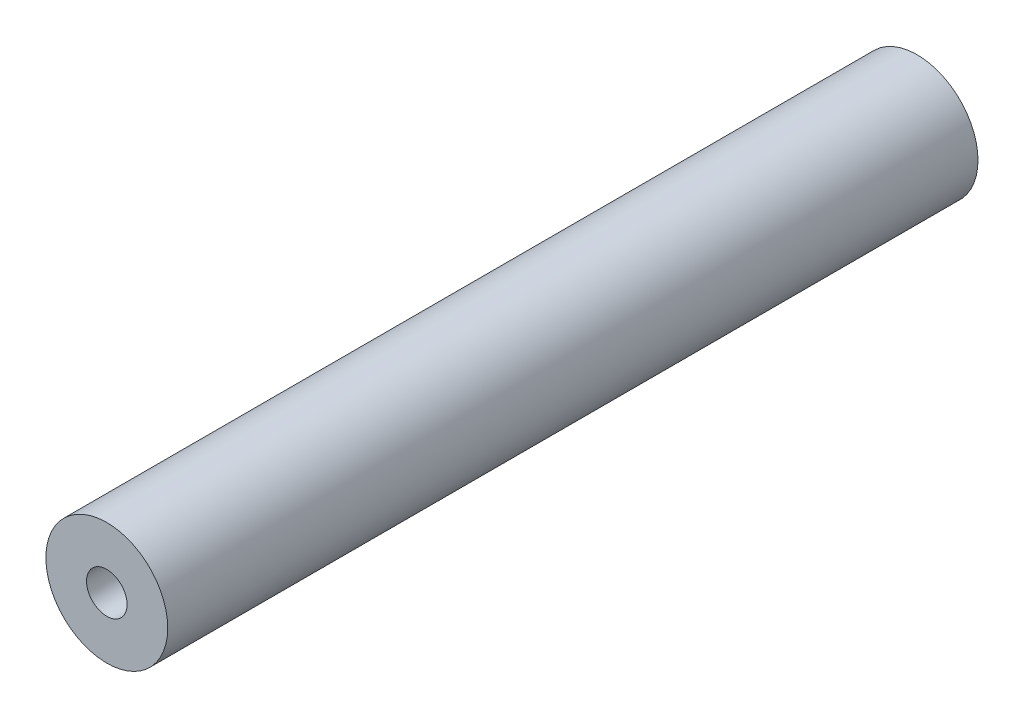
from build123d import *

# Parameters (mm, degrees)
SKETCH1_R           = 3.81
SKETCH1_R_2         = 1.27
BOSS_EXTRUDE1_DEPTH = 50.673


with BuildPart() as part:
    # Sketch1 → Boss-Extrude1 (new body)
    with BuildSketch(Plane.XY):
        Circle(SKETCH1_R)
        Circle(SKETCH1_R_2, mode=Mode.SUBTRACT)
    extrude(amount=-BOSS_EXTRUDE1_DEPTH)


solid = part.part
